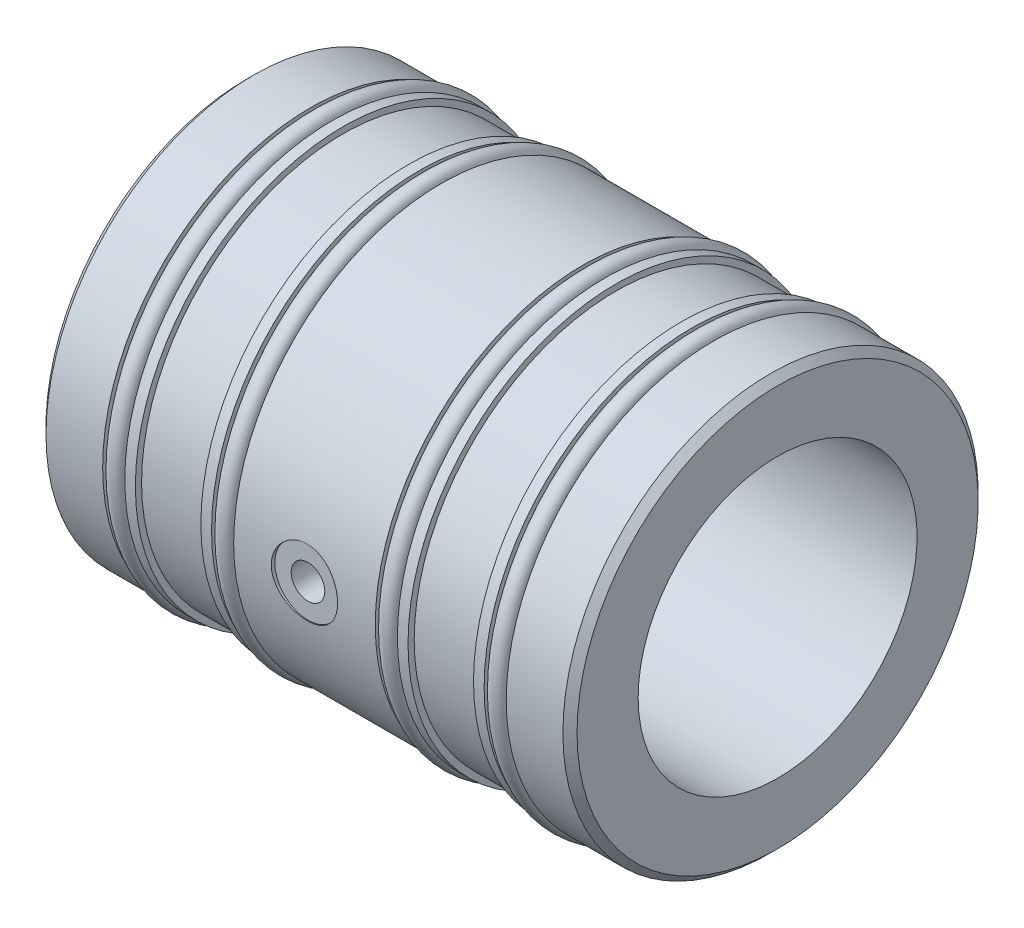
from build123d import *

# Parameters (mm, degrees)
CHAMFER1_SIZE                    = 1.016
F_3_8_0_375_DIAMETER_HOLE1_D     = 9.525
F_3_8_0_375_DIAMETER_HOLE1_DEPTH = 0.51
AIR_HOLE_D                       = 4.0894
AIR_HOLE_DEPTH                   = 6.35
AIR_HOLE_CBORE_D                 = 4.826
AIR_HOLE_CBORE_DEPTH             = 5.994
AIR_HOLE_TIP                     = 1.228579708
SKETCH5_R                        = 1.2827


with BuildPart() as part:
    # Sketch1 → Revolve1 (revolve)
    with BuildSketch(Plane.XY, mode=Mode.PRIVATE) as revolve1_sk:
        Polygon((0, 20.01), (76.2, 20.01), (76.2, 29.7942), (67.055, 29.7942), (67.055, 27.813), (63.88, 27.813), (63.88, 29.7942), (62.358, 29.7942), (62.358, 28.905), (52.96, 28.905), (52.96, 29.7942), (51.435, 29.7942), (51.435, 27.813), (48.26, 27.813), (48.26, 29.7942), (27.945, 29.7942), (27.945, 27.813), (24.77, 27.813), (24.77, 29.7942), (23.238, 29.7942), (23.238, 28.905), (13.84, 28.905), (13.84, 29.7942), (12.319, 29.7942), (12.319, 27.813), (9.144, 27.813), (9.144, 29.7942), (0, 29.7942), align=None)
    revolve(revolve1_sk.sketch.rotate(Axis((0, 0, 0), (1, 0, 0)), 90), axis=Axis((0, 0, 0), (1, 0, 0)))  # turned: the seam where the file's is

    # Chamfer1
    chamfer1_edges = [part.edges().sort_by_distance(p)[0] for p in [
        (76.2, 0, -29.7942),
        (0, 0, -29.7942),
    ]]
    chamfer(chamfer1_edges, length=CHAMFER1_SIZE)

    # 3/8 (0.375) Diameter Hole1
    with Locations(Plane(origin=(38.1, 0, 29.7942), x_dir=(1, 0, 0), z_dir=(0, 0, 1))):
        with Locations((0, 0)):
            Hole(F_3_8_0_375_DIAMETER_HOLE1_D / 2, depth=F_3_8_0_375_DIAMETER_HOLE1_DEPTH)

    # Air Hole
    with Locations(Plane.XY.offset(29.2842)):
        with Locations((38.1, 0)):
            CounterBoreHole(AIR_HOLE_D / 2, AIR_HOLE_CBORE_D / 2, AIR_HOLE_CBORE_DEPTH, depth=AIR_HOLE_DEPTH)
            with Locations((0, 0, -(AIR_HOLE_DEPTH + AIR_HOLE_TIP / 2))):  # 118° drill point
                Cone(0, AIR_HOLE_D / 2, AIR_HOLE_TIP, mode=Mode.SUBTRACT)


with BuildPart() as body_2:
    # Sketch5 → Revolve2 (revolve)
    with BuildSketch(Plane.XY, mode=Mode.PRIVATE) as revolve2_sk:
        with Locations((65.4675, 29.0957)):
            Circle(SKETCH5_R)
        with Locations((49.8475, 29.0957)):
            Circle(SKETCH5_R)
        with Locations((26.3575, 29.0957)):
            Circle(SKETCH5_R)
        with Locations((10.7315, 29.0957)):
            Circle(SKETCH5_R)
    revolve(revolve2_sk.sketch.rotate(Axis((0, 0, 0), (1, 0, 0)), 90), axis=Axis((0, 0, 0), (1, 0, 0)))  # turned: the seam where the file's is


solid = Compound([part.part, body_2.part])
